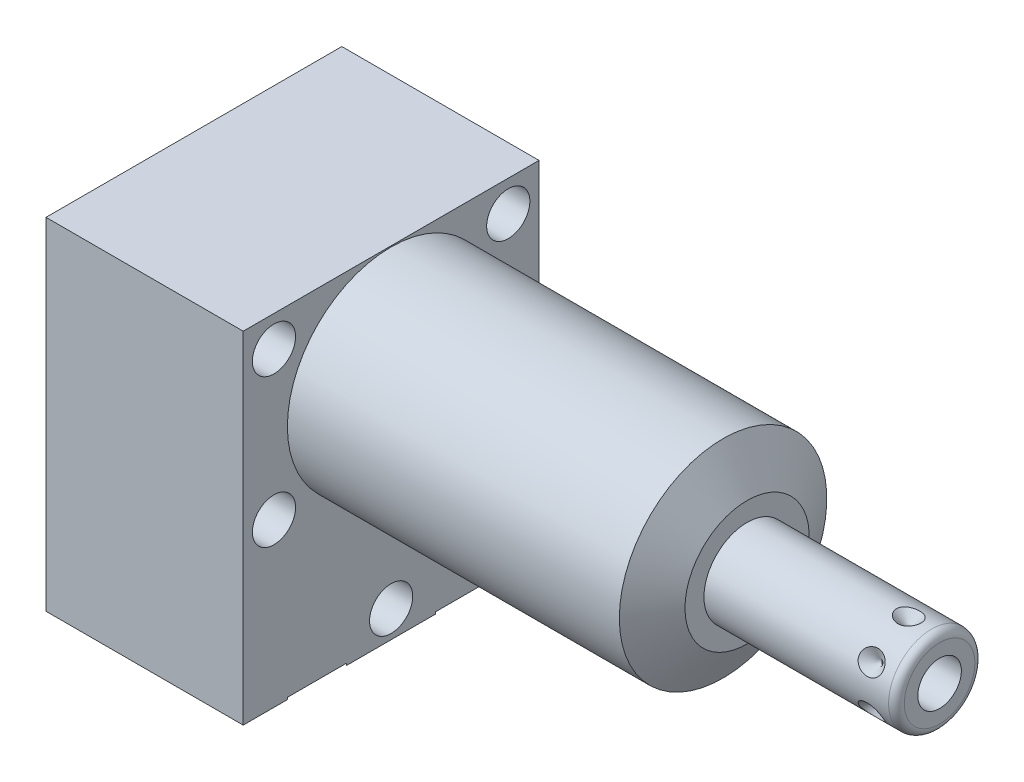
from build123d import *

# Parameters (mm, degrees)
SKETCH1_W           = 38.1
SKETCH1_H           = 43.942
EXTRUDE1_DEPTH      = 45.847
EXTRUDE1_DEPTH_BACK = 25.4
CUT_EXTRUDE1_REACH  = 47.847
SKETCH2_W           = 38.1
SKETCH2_H           = 43.942
SKETCH2_R           = 13.3604
SKETCH14_R          = 7.9375
CUT_EXTRUDE2_DEPTH  = 2.667
SKETCH10_R          = 6.4389
EXTRUDE2_DEPTH      = 1.651
SKETCH11_R          = 4.8006
EXTRUDE3_DEPTH      = 2.667
CIRPATTERN1_COUNT   = 6
HOLE1_D             = 5.5626
HOLE1_DEPTH         = 25.4


with BuildPart() as part:
    # Sketch1 → Extrude1 (new body, two sides)
    with BuildSketch(Plane(origin=(0, 0, 0), x_dir=(0, 0, -1), z_dir=(1, 0, 0))) as extrude1_sk:
        with Locations((0, -8.4836)):
            Rectangle(SKETCH1_W, SKETCH1_H)
    extrude(amount=EXTRUDE1_DEPTH)
    extrude(extrude1_sk.sketch, amount=-EXTRUDE1_DEPTH_BACK)

    # Sketch2 → Cut-Extrude1 (cut, up to next)
    with BuildSketch(Plane(origin=(0, 0, 0), x_dir=(0, 0, -1), z_dir=(1, 0, 0)), mode=Mode.PRIVATE) as cut_extrude1_sk1:
        with Locations((0, -8.4836)):
            Rectangle(SKETCH2_W, SKETCH2_H)
        Circle(SKETCH2_R, mode=Mode.SUBTRACT)
    cut_extrude1_tool1 = extrude(cut_extrude1_sk1.sketch, amount=CUT_EXTRUDE1_REACH, mode=Mode.PRIVATE) & part.part
    add(cut_extrude1_tool1.solids().sort_by_distance((0, 13.429241, 0))[0], mode=Mode.SUBTRACT)

    # Sketch3 → Cut-Revolve1 (revolve, cut)
    with BuildSketch(Plane.XY, mode=Mode.PRIVATE) as cut_revolve1_sk:
        Polygon((42.752748967, 13.3604), (45.847, 8.001), (45.847, 13.3604), align=None)
    revolve(cut_revolve1_sk.sketch.rotate(Axis((42.598036416, 0, 0), (1, 0, 0)), 90), axis=Axis((42.598036416, 0, 0), (1, 0, 0)), mode=Mode.SUBTRACT)  # turned: the seam where the file's is

    # S2D0002 → Cut-Revolve2 (revolve, cut)
    with BuildSketch(Plane(origin=(-22.733, -19.8374, 9.525), x_dir=(0, 1, 0), z_dir=(0, 0, 1)), mode=Mode.PRIVATE) as cut_revolve2_sk:
        Polygon((-0.8128, 0), (3.7338, 0), (3.293786662, -2.0701), (2.6416, -2.722286662), (2.6416, -13.97), (-0.8128, -13.97), align=None)
    revolve(cut_revolve2_sk.sketch.rotate(Axis((-8.0645, -20.6502, 9.525), (-1, 0, 0)), 90), axis=Axis((-8.0645, -20.6502, 9.525), (-1, 0, 0)), mode=Mode.SUBTRACT)  # turned: the seam where the file's is

    # Sketch5 → Cut-Revolve3 (revolve, cut)
    with BuildSketch(Plane(origin=(-22.733, -19.8374, -9.525), x_dir=(0, 1, 0), z_dir=(0, 0, 1)), mode=Mode.PRIVATE) as cut_revolve3_sk:
        Polygon((-0.8128, 0), (3.7338, 0), (3.293786662, -2.0701), (2.6416, -2.722286662), (2.6416, -13.97), (-0.8128, -13.97), align=None)
    revolve(cut_revolve3_sk.sketch.rotate(Axis((-8.0645, -20.6502, -9.525), (-1, 0, 0)), 90), axis=Axis((-8.0645, -20.6502, -9.525), (-1, 0, 0)), mode=Mode.SUBTRACT)  # turned: the seam where the file's is

    # Sketch14 → Cut-Extrude2 (cut)
    with BuildSketch(Plane.ZY.offset(25.4)):
        with Locations((-9.525, -20.6502)):
            Circle(SKETCH14_R)
        with Locations((9.525, -20.6502)):
            Circle(SKETCH14_R)
    extrude(amount=-CUT_EXTRUDE2_DEPTH, mode=Mode.SUBTRACT)

    # Sketch6 → Cut-Revolve4 (revolve, cut)
    with BuildSketch(Plane(origin=(-8.7376, -30.2006, 9.525), x_dir=(-1, 0, 0), z_dir=(0, 0, 1)), mode=Mode.PRIVATE) as cut_revolve4_sk:
        Polygon((6.18363, 0), (5.641036865, -2.5527), (4.97713, -3.216606865), (4.97713, -17.272), (0, -17.272), (0, 0), (0, 0.254), (9.52373, 0.254), (9.52373, 0), align=None)
    revolve(cut_revolve4_sk.sketch.rotate(Axis((-8.7376, -12.065, 9.525), (0, -1, 0)), 270), axis=Axis((-8.7376, -12.065, 9.525), (0, -1, 0)), mode=Mode.SUBTRACT)  # turned: the seam where the file's is

    # Sketch7 → Cut-Revolve5 (revolve, cut)
    with BuildSketch(Plane(origin=(-8.7376, -30.2006, -9.525), x_dir=(-1, 0, 0), z_dir=(0, 0, 1)), mode=Mode.PRIVATE) as cut_revolve5_sk:
        Polygon((6.1849, 0), (5.642306865, -2.5527), (4.9784, -3.216606865), (4.9784, -17.272), (0, -17.272), (0, 0), (0, 0.254), (9.52373, 0.254), (9.52373, 0), align=None)
    revolve(cut_revolve5_sk.sketch.rotate(Axis((-8.7376, -12.065, -9.525), (0, -1, 0)), 270), axis=Axis((-8.7376, -12.065, -9.525), (0, -1, 0)), mode=Mode.SUBTRACT)  # turned: the seam where the file's is

    # Sketch8 → Revolve1 (revolve)
    with BuildSketch(Plane.XY, mode=Mode.PRIVATE) as revolve1_sk:
        with BuildLine():
            Line((45.847, 0), (45.847, 5.55625))
            Line((45.847, 5.55625), (69.6214, 5.55625))
            ThreePointArc((69.6214, 5.55625), (70.33982049, 5.25867049), (70.6374, 4.54025))
            Line((70.6374, 4.54025), (70.6374, 0))
            Line((70.6374, 0), (45.847, 0))
        make_face()
    revolve(revolve1_sk.sketch.rotate(Axis((44.83227, 0, 0), (1, 0, 0)), 90), axis=Axis((44.83227, 0, 0), (1, 0, 0)))  # turned: the seam where the file's is

    # S2D0001 → Cut-Revolve6 (revolve, cut)
    with BuildSketch(Plane(origin=(66.1416, -2.8067, 0), x_dir=(0, -1, 0), z_dir=(0, 0, 1)), mode=Mode.PRIVATE) as cut_revolve6_sk:
        Polygon((0, 4.4958), (0, -5.6642), (-2.8067, -7.350635499), (-2.8067, 4.4958), align=None)
    revolve(cut_revolve6_sk.sketch.rotate(Axis((53.702842726, 0, 0), (1, 0, 0)), 270), axis=Axis((53.702842726, 0, 0), (1, 0, 0)), mode=Mode.SUBTRACT)  # turned: the seam where the file's is

    # Sketch10 → Extrude2 (add)
    with BuildSketch(Plane(origin=(-25.4, -30.2006, 0), x_dir=(0, 0, -1), z_dir=(0, -1, 0))):
        with Locations(Location((-9.525, 16.6624, 0), (0, 0, 180))):  # turned: the seam where the file's is
            Circle(SKETCH10_R)
    extrude(amount=EXTRUDE2_DEPTH)

    # Sketch11 → Extrude3 (add)
    with BuildSketch(Plane.ZY.offset(22.733)):
        with Locations(Location((9.525, -20.6502, 0), (0, 0, 180))):  # turned: the seam where the file's is
            Circle(SKETCH11_R)
    extrude(amount=EXTRUDE3_DEPTH)

    # Sketch12 → Cut-Revolve7 (revolve, cut)
    with BuildSketch(Plane(origin=(62.1792, -5.55625, 0), x_dir=(-1, 0, 0), z_dir=(0, 0, 1)), mode=Mode.PRIVATE) as cut_revolve7_sk:
        Polygon((-4.4958, 0), (-2.9083, 0), (-4.4958, -1.5875), align=None)
    cut_revolve7 = revolve(cut_revolve7_sk.sketch.rotate(Axis((66.675, -2.12229387, 0), (0, -1, 0)), 90), axis=Axis((66.675, -2.12229387, 0), (0, -1, 0)), mode=Mode.SUBTRACT)  # turned: the seam where the file's is

    # CirPattern1: Cut-Revolve7 ×6 about axis
    cirpattern1_axis = Axis((45.848, 0, 0), (-1, 0, 0))
    for i in range(1, CIRPATTERN1_COUNT):
        add(cut_revolve7.rotate(cirpattern1_axis, i * 360 / CIRPATTERN1_COUNT), mode=Mode.SUBTRACT)

    # Hole1
    with Locations(Plane(origin=(0, 0, 0), x_dir=(0, 0, -1), z_dir=(1, 0, 0))):
        with Locations((-15.0876, 9.525), (-15.0876, -9.525), (15.0876, 9.525), (15.0876, -9.525), (0, -26.9748)):
            Hole(HOLE1_D / 2, depth=HOLE1_DEPTH)


solid = part.part
